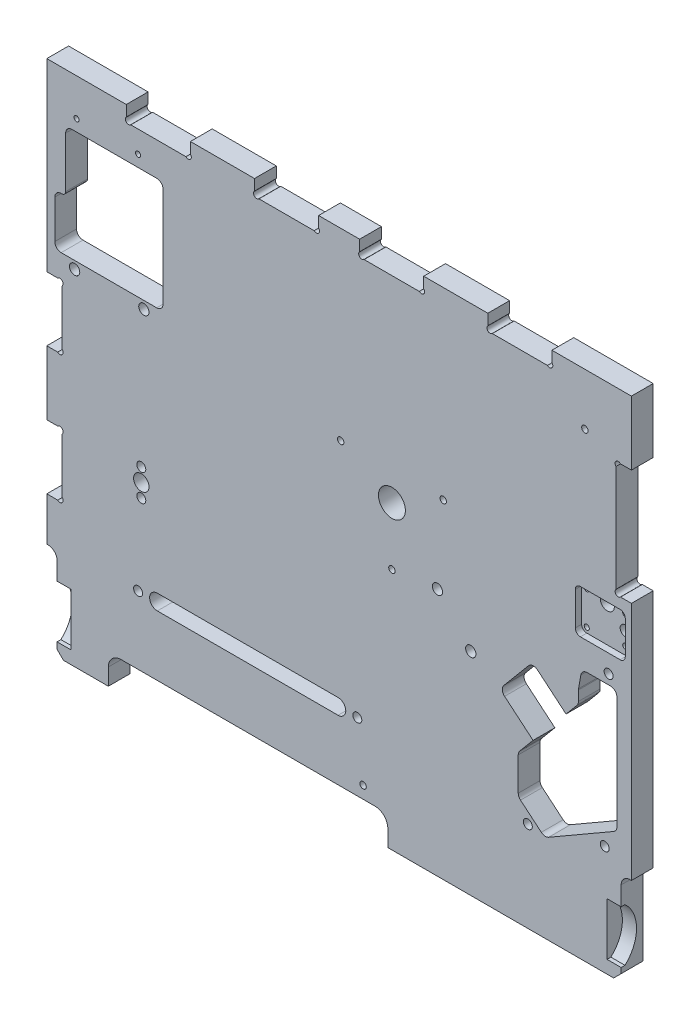
from build123d import *

# Parameters (mm, degrees)
CROQUIS1_R              = 2
CROQUIS1_R_2            = 4
CROQUIS1_R_3            = 2.5
CROQUIS1_R_4            = 10.5
CROQUIS1_R_5            = 3.5
CROQUIS1_R_6            = 6
CROQUIS1_R_7            = 5.5
SALIENTE_EXTRUIR1_DEPTH = 17
CORTAR_EXTRUIR8_DEPTH   = 2
CORTAR_EXTRUIR9_DEPTH   = 4
CROQUIS4_R              = 7.5
CORTAR_EXTRUIR10_DEPTH  = 12
CORTAR_EXTRUIR11_DEPTH  = 11
CORTAR_EXTRUIR12_DEPTH  = 11
CORTAR_EXTRUIR13_DEPTH  = 5


with BuildPart() as part:
    # Croquis1 → Saliente-Extruir1 (new body)
    with BuildSketch(Plane.XY):
        with BuildLine():
            Line((-229.108420579, -41.08967784), (-167.108420579, -41.08967784))
            Line((-167.108420579, -41.08967784), (-167.108420579, -49.58967784))
            ThreePointArc((-167.108420579, -49.58967784), (-167.108420579, -53.08967784), (-163.608420579, -53.08967784))
            Line((-163.608420579, -53.08967784), (-120.608420579, -53.08967784))
            ThreePointArc((-120.608420579, -53.08967784), (-117.108420579, -53.08967784), (-117.108420579, -49.58967784))
            Line((-117.108420579, -49.58967784), (-117.108420579, -41.08967784))
            Line((-117.108420579, -41.08967784), (-67.108420579, -41.08967784))
            Line((-67.108420579, -41.08967784), (-67.108420579, -49.58967784))
            ThreePointArc((-67.108420579, -49.58967784), (-67.108420579, -53.08967784), (-63.608420579, -53.08967784))
            Line((-63.608420579, -53.08967784), (-20.608420579, -53.08967784))
            ThreePointArc((-20.608420579, -53.08967784), (-17.108420579, -53.08967784), (-17.108420579, -49.58967784))
            Line((-17.108420579, -49.58967784), (-17.108420579, -41.08967784))
            Line((-17.108420579, -41.08967784), (14.891579421, -41.08967784))
            Line((14.891579421, -41.08967784), (14.891579421, -49.58967784))
            ThreePointArc((14.891579421, -49.58967784), (14.891579421, -53.08967784), (18.391579421, -53.08967784))
            Line((18.391579421, -53.08967784), (61.391579421, -53.08967784))
            ThreePointArc((61.391579421, -53.08967784), (64.891579421, -53.08967784), (64.891579421, -49.58967784))
            Line((64.891579421, -49.58967784), (64.891579421, -41.08967784))
            Line((64.891579421, -41.08967784), (114.891579421, -41.08967784))
            Line((114.891579421, -41.08967784), (114.891579421, -49.58967784))
            ThreePointArc((114.891579421, -49.58967784), (114.891579421, -53.08967784), (118.391579421, -53.08967784))
            Line((118.391579421, -53.08967784), (161.391579421, -53.08967784))
            ThreePointArc((161.391579421, -53.08967784), (164.891579421, -53.08967784), (164.891579421, -49.58967784))
            Line((164.891579421, -49.58967784), (164.891579421, -41.08967784))
            Line((164.891579421, -41.08967784), (226.891579421, -41.08967784))
            Line((226.891579421, -41.08967784), (226.891579421, -91.08967784))
            Line((226.891579421, -91.08967784), (218.391579421, -91.08967784))
            ThreePointArc((218.391579421, -91.08967784), (214.891579421, -91.08967784), (214.891579421, -94.58967784))
            Line((214.891579421, -94.58967784), (214.891579421, -177.58967784))
            ThreePointArc((214.891579421, -177.58967784), (214.891579421, -181.08967784), (218.391579421, -181.08967784))
            Line((218.391579421, -181.08967784), (226.891579421, -181.08967784))
            Line((226.891579421, -181.08967784), (226.891579421, -368.32657874))
            ThreePointArc((226.891579421, -368.32657874), (221.309003726, -369.963279348), (218.891579421, -375.25478197))
            Line((218.891579421, -375.25478197), (218.891579421, -435.25478197))
            Line((218.891579421, -435.25478197), (213.056683551, -441.08967784))
            Line((213.056683551, -441.08967784), (36.891579421, -441.08967784))
            Line((36.891579421, -441.08967784), (36.891579421, -428.08967784))
            ThreePointArc((36.891579421, -428.08967784), (33.962647233, -421.018610028), (26.891579421, -418.08967784))
            Line((26.891579421, -418.08967784), (-171.108420579, -418.08967784))
            ThreePointArc((-171.108420579, -418.08967784), (-178.179488391, -421.018610028), (-181.108420579, -428.08967784))
            Line((-181.108420579, -428.08967784), (-181.108420579, -441.08967784))
            Line((-181.108420579, -441.08967784), (-216.108420579, -441.08967784))
            Line((-216.108420579, -441.08967784), (-221.108420579, -436.08967784))
            Line((-221.108420579, -436.08967784), (-221.108420579, -376.08967784))
            ThreePointArc((-221.108420579, -376.08967784), (-223.525844884, -370.798175218), (-229.108420579, -369.16147461))
            Line((-229.108420579, -369.16147461), (-229.108420579, -335.08967784))
            Line((-229.108420579, -335.08967784), (-220.608420579, -335.08967784))
            ThreePointArc((-220.608420579, -335.08967784), (-217.108420579, -335.08967784), (-217.108420579, -331.58967784))
            Line((-217.108420579, -331.58967784), (-217.108420579, -288.58967784))
            ThreePointArc((-217.108420579, -288.58967784), (-217.108420579, -285.08967784), (-220.608420579, -285.08967784))
            Line((-220.608420579, -285.08967784), (-229.108420579, -285.08967784))
            Line((-229.108420579, -285.08967784), (-229.108420579, -235.08967784))
            Line((-229.108420579, -235.08967784), (-220.608420579, -235.08967784))
            ThreePointArc((-220.608420579, -235.08967784), (-217.108420579, -235.08967784), (-217.108420579, -231.58967784))
            Line((-217.108420579, -231.58967784), (-217.108420579, -188.58967784))
            ThreePointArc((-217.108420579, -188.58967784), (-217.108420579, -185.08967784), (-220.608420579, -185.08967784))
            Line((-220.608420579, -185.08967784), (-229.108420579, -185.08967784))
            Line((-229.108420579, -185.08967784), (-229.108420579, -41.08967784))
        make_face()
        with Locations((-205.901630387, -70.08967784)):
            Circle(CROQUIS1_R, mode=Mode.SUBTRACT)
        with Locations((-157.901630387, -70.08967784)):
            Circle(CROQUIS1_R, mode=Mode.SUBTRACT)
        with Locations((-207.401630387, -172.58967784)):
            Circle(CROQUIS1_R_2, mode=Mode.SUBTRACT)
        with Locations((-153.401630387, -172.58967784)):
            Circle(CROQUIS1_R_2, mode=Mode.SUBTRACT)
        with Locations((190.598369613, -81.58967784)):
            Circle(CROQUIS1_R_3, mode=Mode.SUBTRACT)
        with Locations((40.098369613, -206.58967784)):
            Circle(CROQUIS1_R_4, mode=Mode.SUBTRACT)
        with Locations((0.098369613, -184.58967784)):
            Circle(CROQUIS1_R_3, mode=Mode.SUBTRACT)
        with Locations((209.127331721, -237.58967784)):
            Circle(CROQUIS1_R_5, mode=Mode.SUBTRACT)
        with Locations((206.098369613, -355.58967784)):
            Circle(CROQUIS1_R_5, mode=Mode.SUBTRACT)
        with Locations((146.098369613, -370.58967784)):
            Circle(CROQUIS1_R_5, mode=Mode.SUBTRACT)
        with Locations((-155.401630387, -290.58967784)):
            Circle(CROQUIS1_R_6, mode=Mode.SUBTRACT)
        with Locations((-155.401630387, -280.08967784)):
            Circle(CROQUIS1_R_5, mode=Mode.SUBTRACT)
        with Locations((-155.401630387, -301.08967784)):
            Circle(CROQUIS1_R_5, mode=Mode.SUBTRACT)
        with Locations((-157.901630387, -365.08967784)):
            Circle(CROQUIS1_R_5, mode=Mode.SUBTRACT)
        with Locations((13.098369613, -365.08967784)):
            Circle(CROQUIS1_R_5, mode=Mode.SUBTRACT)
        with Locations((80.098369613, -184.58967784)):
            Circle(CROQUIS1_R_3, mode=Mode.SUBTRACT)
        with Locations((40.098369613, -251.58967784)):
            Circle(CROQUIS1_R_3, mode=Mode.SUBTRACT)
        with Locations((75.598369613, -247.08967784)):
            Circle(CROQUIS1_R_2, mode=Mode.SUBTRACT)
        with Locations((101.598369613, -276.08967784)):
            Circle(CROQUIS1_R_2, mode=Mode.SUBTRACT)
        with Locations((17.598369613, -408.58967784)):
            Circle(CROQUIS1_R_3, mode=Mode.SUBTRACT)
        with Locations((203.098369613, -195.08967784)):
            Circle(CROQUIS1_R_7, mode=Mode.SUBTRACT)
        with Locations((187.098369613, -193.58967784)):
            Circle(CROQUIS1_R, mode=Mode.SUBTRACT)
        with Locations((217.098369613, -195.58967784)):
            Circle(CROQUIS1_R, mode=Mode.SUBTRACT)
        with Locations((187.098369613, -219.58967784)):
            Circle(CROQUIS1_R, mode=Mode.SUBTRACT)
        with Locations((217.098369613, -217.58967784)):
            Circle(CROQUIS1_R, mode=Mode.SUBTRACT)
        with Locations((217.098369613, -207.06350524)):
            Circle(CROQUIS1_R_2, mode=Mode.SUBTRACT)
        with BuildLine():
            Line((-209.401630387, -79.08967784), (-143.401630387, -79.08967784))
            ThreePointArc((-143.401630387, -79.08967784), (-139.866096481, -80.554143934), (-138.401630387, -84.08967784))
            Line((-138.401630387, -84.08967784), (-138.401630387, -161.58967784))
            ThreePointArc((-138.401630387, -161.58967784), (-139.866096481, -165.125211746), (-143.401630387, -166.58967784))
            Line((-143.401630387, -166.58967784), (-217.901630387, -166.58967784))
            ThreePointArc((-217.901630387, -166.58967784), (-221.437164293, -165.125211746), (-222.901630387, -161.58967784))
            Line((-222.901630387, -161.58967784), (-222.901630387, -131.58967784))
            ThreePointArc((-222.901630387, -131.58967784), (-221.437164293, -128.054143934), (-217.901630387, -126.58967784))
            Line((-217.901630387, -126.58967784), (-217.401630387, -126.58967784))
            ThreePointArc((-217.401630387, -126.58967784), (-215.280310043, -125.710998183), (-214.401630387, -123.58967784))
            Line((-214.401630387, -123.58967784), (-214.401630387, -84.08967784))
            ThreePointArc((-214.401630387, -84.08967784), (-212.937164293, -80.554143934), (-209.401630387, -79.08967784))
        make_face(mode=Mode.SUBTRACT)
        with BuildLine():
            Line((-142.901630387, -359.08967784), (-1.901630387, -359.08967784))
            ThreePointArc((-1.901630387, -359.08967784), (4.098369613, -365.08967784), (-1.901630387, -371.08967784))
            Line((-1.901630387, -371.08967784), (-142.901630387, -371.08967784))
            ThreePointArc((-142.901630387, -371.08967784), (-148.901630387, -365.08967784), (-142.901630387, -359.08967784))
        make_face(mode=Mode.SUBTRACT)
        with BuildLine():
            Line((215.598369613, -250.08967784), (215.598369613, -337.751552598))
            ThreePointArc((215.598369613, -337.751552598), (214.928496632, -340.251552598), (213.098369613, -342.081679617))
            Line((213.098369613, -342.081679617), (162.338705947, -371.387785099))
            ThreePointArc((162.338705947, -371.387785099), (159.402927234, -372.03863157), (156.624767899, -370.887880295))
            Line((156.624767899, -370.887880295), (140.409580355, -357.281722408))
            ThreePointArc((140.409580355, -357.281722408), (139.091979468, -355.564591501), (138.623518403, -353.451500192))
            Line((138.623518403, -353.451500192), (138.623518403, -327.602889654))
            ThreePointArc((138.623518403, -327.602889654), (138.925055299, -325.892788937), (139.793296187, -324.388951606))
            Line((139.793296187, -324.388951606), (150.193695377, -311.994238507))
            Line((150.193695377, -311.994238507), (127.978406527, -293.353397826))
            ThreePointArc((127.978406527, -293.353397826), (126.211371085, -289.958954324), (127.36212236, -286.309237562))
            Line((127.36212236, -286.309237562), (146.64575065, -263.327904268))
            ThreePointArc((146.64575065, -263.327904268), (150.040194152, -261.560868826), (153.689910914, -262.711620101))
            Line((153.689910914, -262.711620101), (175.905199765, -281.352460782))
            Line((175.905199765, -281.352460782), (184.377236126, -271.255881012))
            ThreePointArc((184.377236126, -271.255881012), (185.245477014, -269.75204368), (185.54701391, -268.041942964))
            Line((185.54701391, -268.041942964), (185.54701391, -260.299237453))
            ThreePointArc((185.54701391, -260.299237453), (185.56604042, -259.863458739), (185.622975145, -259.430996564))
            Line((185.622975145, -259.430996564), (187.423195966, -249.221436951))
            ThreePointArc((187.423195966, -249.221436951), (189.133296683, -246.259455624), (192.347234731, -245.08967784))
            Line((192.347234731, -245.08967784), (210.598369613, -245.08967784))
            ThreePointArc((210.598369613, -245.08967784), (214.133903519, -246.554143934), (215.598369613, -250.08967784))
        make_face(mode=Mode.SUBTRACT)
    extrude(amount=SALIENTE_EXTRUIR1_DEPTH)

    # Desbaste Ranura 2mm → Cortar-Extruir8 (cut)
    with BuildSketch(Plane.XY):
        with BuildLine():
            Line((-1.901630387, -371.08967784), (-3.069579716, -371.08967784))
            Line((-3.069579716, -371.08967784), (71.092991441, -422.022596736))
            ThreePointArc((71.092991441, -422.022596736), (72.732886227, -422.822110601), (74.534772935, -423.107910566))
            Line((74.534772935, -423.107910566), (86.57829589, -422.93057538))
            Line((86.57829589, -422.93057538), (134.20989255, -409.030288848))
            ThreePointArc((134.20989255, -409.030288848), (138.675914407, -406.164986943), (140.87529161, -401.336110659))
            Line((140.87529161, -401.336110659), (135.287295848, -368.869389045))
            ThreePointArc((135.287295848, -368.869389045), (127.946229575, -363.684262958), (122.761103488, -371.025329231))
            Line((122.761103488, -371.025329231), (127.589134414, -399.076591741))
            Line((127.589134414, -399.076591741), (85.670305829, -410.970654404))
            Line((85.670305829, -410.970654404), (76.402504816, -411.074834221))
            Line((76.402504816, -411.074834221), (19.098369613, -370.963544087))
            Line((19.098369613, -370.963544087), (19.098369613, -364.08967784))
            ThreePointArc((19.098369613, -364.08967784), (13.098320996, -358.08967784), (7.098369614, -364.089775074))
            Line((7.098369614, -364.089775074), (4.080517729, -364.552175317))
            ThreePointArc((4.080517729, -364.552175317), (2.529087256, -369.138273857), (-1.901630387, -371.08967784))
        make_face()
    extrude(amount=CORTAR_EXTRUIR8_DEPTH, mode=Mode.SUBTRACT)

    # Croquis8 → Cortar-Extruir9 (cut)
    with BuildSketch(Plane.XY):
        with BuildLine():
            Line((-165.401630387, -301.08967784), (-165.401630387, -280.08967784))
            ThreePointArc((-165.401630387, -280.08967784), (-155.401630387, -270.08967784), (-145.401630387, -280.08967784))
            Line((-145.401630387, -280.08967784), (-145.401630387, -301.08967784))
            ThreePointArc((-145.401630387, -301.08967784), (-155.401630387, -311.08967784), (-165.401630387, -301.08967784))
        make_face()
    extrude(amount=CORTAR_EXTRUIR9_DEPTH, mode=Mode.SUBTRACT)

    # Croquis4 → Cortar-Extruir10 (cut)
    with BuildSketch(Plane(origin=(0, 0, 0), x_dir=(-1, 0, 0), z_dir=(0, 0, -1))):
        with Locations((198.901630387, -416.573024462)):
            Circle(CROQUIS4_R)
    extrude(amount=-CORTAR_EXTRUIR10_DEPTH, mode=Mode.SUBTRACT)

    # Vis Der → Cortar-Extruir11 (cut)
    with BuildSketch(Plane(origin=(218.891579421, 0, 0), x_dir=(0, 0, -1), z_dir=(1, 0, 0))):
        with BuildLine():
            Line((-17, -390.08967784), (-17, -431.08967784))
            Line((-17, -431.08967784), (-14, -431.08967784))
            ThreePointArc((-14, -431.08967784), (-5, -410.58967784), (-14, -390.08967784))
            Line((-14, -390.08967784), (-17, -390.08967784))
        make_face()
    extrude(amount=-CORTAR_EXTRUIR11_DEPTH, mode=Mode.SUBTRACT)

    # Vis Izq → Cortar-Extruir12 (cut)
    with BuildSketch(Plane.ZY.offset(221.108420579)):
        with BuildLine():
            Line((17, -390.08967784), (14, -390.08967784))
            ThreePointArc((14, -390.08967784), (5, -410.58967784), (14, -431.08967784))
            Line((14, -431.08967784), (17, -431.08967784))
            Line((17, -431.08967784), (17, -390.08967784))
        make_face()
    extrude(amount=-CORTAR_EXTRUIR12_DEPTH, mode=Mode.SUBTRACT)

    # Base Brazo → Cortar-Extruir13 (cut)
    with BuildSketch(Plane.XY.offset(17)):
        with BuildLine():
            Line((222.098369613, -219.58967784), (222.098369613, -193.58967784))
            ThreePointArc((222.098369613, -193.58967784), (220.926796738, -190.761250715), (218.098369613, -189.58967784))
            Line((218.098369613, -189.58967784), (187.098369613, -189.58967784))
            ThreePointArc((187.098369613, -189.58967784), (184.269942488, -190.761250715), (183.098369613, -193.58967784))
            Line((183.098369613, -193.58967784), (183.098369613, -219.58967784))
            ThreePointArc((183.098369613, -219.58967784), (184.269942488, -222.418104965), (187.098369613, -223.58967784))
            Line((187.098369613, -223.58967784), (218.098369613, -223.58967784))
            ThreePointArc((218.098369613, -223.58967784), (220.926796738, -222.418104965), (222.098369613, -219.58967784))
        make_face()
    extrude(amount=-CORTAR_EXTRUIR13_DEPTH, mode=Mode.SUBTRACT)


solid = part.part
